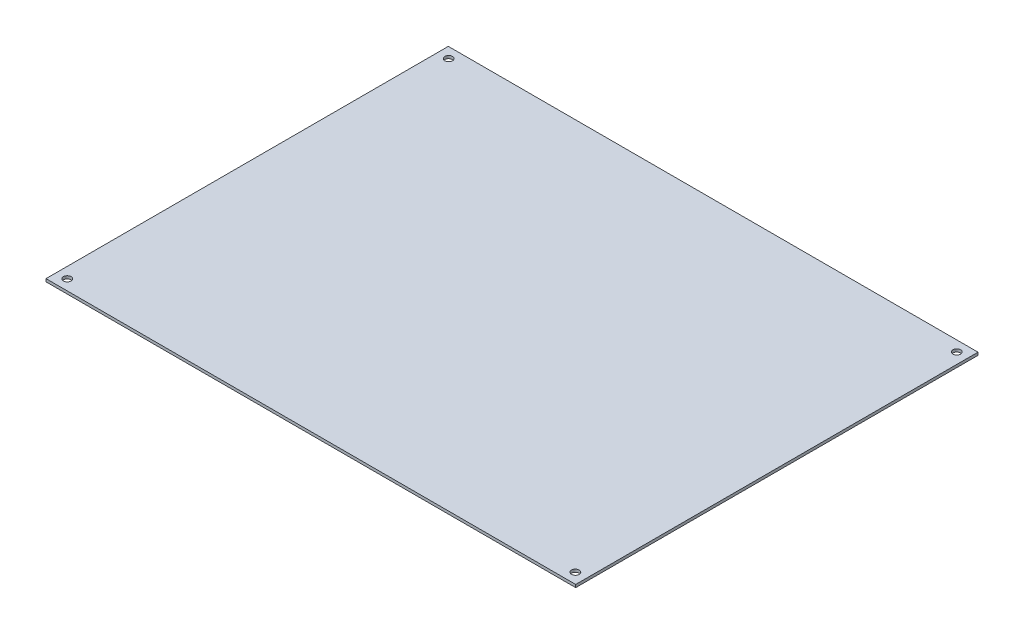
from build123d import *

# Parameters (mm, degrees)
SKETCH9_W            = 380.5
SKETCH9_H            = 289
BOSS_EXTRUDE2_DEPTH  = 2
M5_CLEARANCE_HOLE1_D = 5.5
MIRROR2_COPY_1_D     = 5.5


with BuildPart() as part:
    # Sketch9 → Boss-Extrude2 (new body)
    with BuildSketch(Plane(origin=(0, 0, 0), x_dir=(1, 0, 0), z_dir=(0, 1, 0))):
        Rectangle(SKETCH9_W, SKETCH9_H)
    extrude(amount=BOSS_EXTRUDE2_DEPTH)

    # M5 Clearance Hole1 (through all)
    with Locations(Plane(origin=(0, 2, 0), x_dir=(1, 0, 0), z_dir=(0, 1, 0))):
        with Locations((182.5, 137)):
            m5_clearance_hole1 = Hole(M5_CLEARANCE_HOLE1_D / 2)

    # Mirror1: M5 Clearance Hole1 across plane
    add(m5_clearance_hole1.mirror(Plane.XY), mode=Mode.SUBTRACT)

    # Mirror2: M5 Clearance Hole1 across plane
    add(m5_clearance_hole1.mirror(Plane(origin=(0, 0, 0), x_dir=(0, 0, 1), z_dir=(1, 0, 0))), mode=Mode.SUBTRACT)

    # Mirror2 copy 1 (through all)
    with Locations(Plane(origin=(0, 2, 0), x_dir=(-1, 0, 0), z_dir=(0, 1, 0))):
        with Locations((182.5, 137)):
            Hole(MIRROR2_COPY_1_D / 2)


solid = part.part
